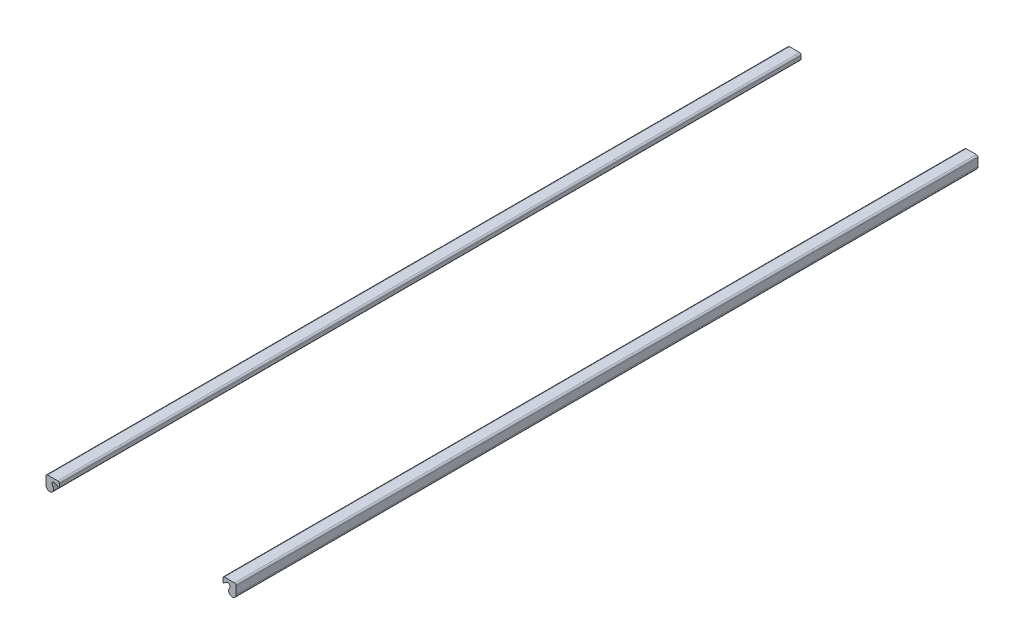
from build123d import *

# Parameters (mm, degrees)
TINY_RED_DEPTH   = 27.7
TINY_RED_2_DEPTH = 27.7


with BuildPart() as part:
    # Tiny Red Profile → Tiny Red (new body, symmetric)
    with BuildSketch(Plane.XY):
        with BuildLine():
            Line((-7.1, 4.582842712), (-7.1, 5.18))
            ThreePointArc((-7.1, 5.18), (-7.064852814, 5.264852814), (-6.98, 5.3))
            Line((-6.98, 5.3), (-6.22, 5.3))
            ThreePointArc((-6.22, 5.3), (-6.135147186, 5.264852814), (-6.1, 5.18))
            Line((-6.1, 5.18), (-6.1, 4.920710678))
            ThreePointArc((-6.1, 4.920710678), (-6.13236303, 4.873924598), (-6.187557492, 4.887704091))
            add(Edge.make_bspline(
                [(-6.187557492, 4.887704091), (-6.389214842, 5.117165695), (-6.561872943, 5.049237628), (-6.734531044, 4.981309562), (-6.578122573, 4.734045904)],
                knots=[1.458408765, 1.458408765, 1.458408765, 2.897791101, 2.897791101, 4.337173437, 4.337173437, 4.337173437], degree=2, weights=[1, 0.752009332, 1, 0.752009332, 1]))
            ThreePointArc((-6.578122573, 4.734045904), (-6.73844651, 4.311172667), (-7.1, 4.582842712))
        make_face()
    extrude(amount=TINY_RED_DEPTH, both=True)


with BuildPart() as body_2:
    # Tiny Red Profile → Tiny Red 2 (new body, symmetric)
    with BuildSketch(Plane.XY):
        with BuildLine():
            Line((7.1, 4.582842712), (7.1, 5.18))
            ThreePointArc((7.1, 5.18), (7.064852814, 5.264852814), (6.98, 5.3))
            Line((6.98, 5.3), (6.22, 5.3))
            ThreePointArc((6.22, 5.3), (6.135147186, 5.264852814), (6.1, 5.18))
            Line((6.1, 5.18), (6.1, 4.920710678))
            ThreePointArc((6.1, 4.920710678), (6.13236303, 4.873924598), (6.187557492, 4.887704091))
            add(Edge.make_bspline(
                [(6.578122573, 4.734045904), (6.734531044, 4.981309562), (6.561872943, 5.049237628), (6.389214842, 5.117165695), (6.187557492, 4.887704091)],
                knots=[1.946011871, 1.946011871, 1.946011871, 3.385394206, 3.385394206, 4.824776542, 4.824776542, 4.824776542], degree=2, weights=[1, 0.752009332, 1, 0.752009332, 1]))
            ThreePointArc((6.578122573, 4.734045904), (6.73844651, 4.311172667), (7.1, 4.582842712))
        make_face()
    extrude(amount=TINY_RED_2_DEPTH, both=True)


solid = Compound([part.part, body_2.part])
